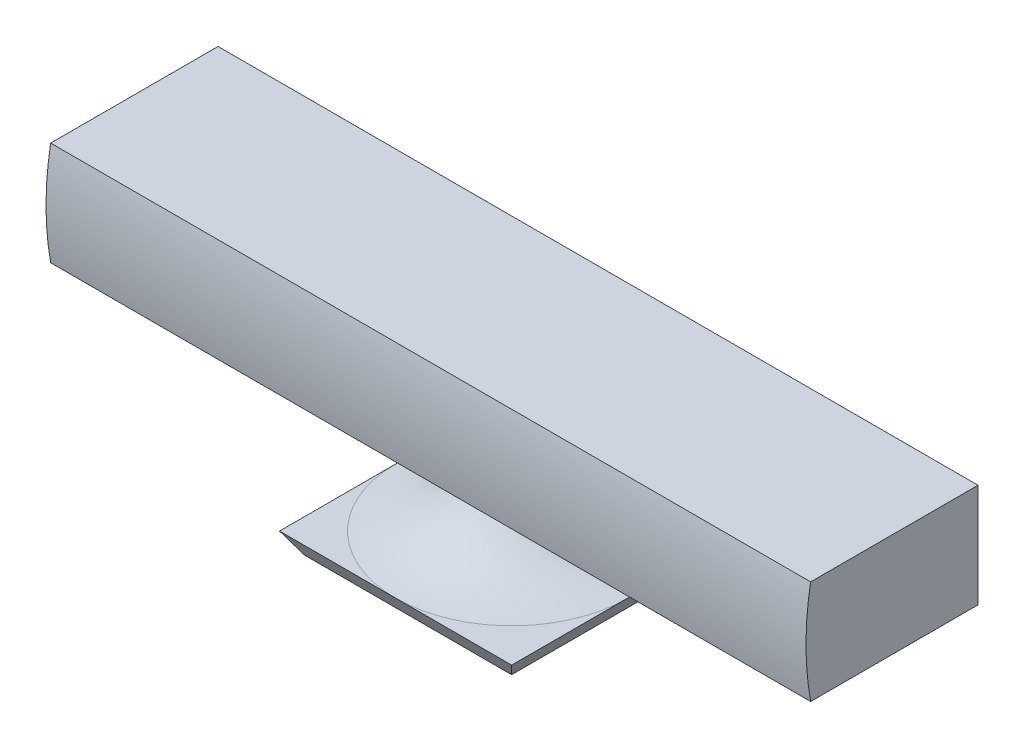
from build123d import *

# Parameters (mm, degrees)
BOSS_EXTRUDE1_DEPTH      = 31.75
BOSS_EXTRUDE1_DEPTH_BACK = 31.75
SKETCH1_W                = 279.4
SKETCH1_H                = 38.1
SKETCH2_W                = 85.344
SKETCH2_H                = 85.344
BOSS_EXTRUDE2_DEPTH      = 38.1
CUT_EXTRUDE3_DEPTH       = 174.39495625
CUT_EXTRUDE4_DEPTH       = 157.853792088
CUT_EXTRUDE4_DEPTH_BACK  = 157.853792088
CUT_EXTRUDE5_DEPTH       = 289.359813588


with BuildPart() as part:
    # Sketch1 → Boss-Extrude1 (new, two sides: drawn at the far end of the back side and taken through both)
    with BuildSketch(Plane.XY.offset(-BOSS_EXTRUDE1_DEPTH_BACK)):
        Rectangle(SKETCH1_W, SKETCH1_H)
    extrude(amount=BOSS_EXTRUDE1_DEPTH + BOSS_EXTRUDE1_DEPTH_BACK)

    # Sketch2 → Boss-Extrude2 (add)
    with BuildSketch(Plane.XZ.offset(19.05)):
        Rectangle(SKETCH2_W, SKETCH2_H)
    extrude(amount=BOSS_EXTRUDE2_DEPTH)

    # Sketch3 → Cut-Revolve8 (revolve, cut)
    with BuildSketch(Plane.XY):
        with BuildLine():
            Line((-42.672, -49.517710244), (-67.10297317, -49.517710244))
            Line((-67.10297317, -49.517710244), (-67.10297317, -19.05))
            Line((-67.10297317, -19.05), (-6.167552681, -19.05))
            add(Edge.make_bspline(
                [(-42.672, -49.517710244), (-14.406584367, -46.12312834), (-6.167552681, -19.05)],
                knots=[0, 0, 0, 1, 1, 1], degree=2))
        make_face()
    revolve(axis=Axis((0, -19.05, 0), (0, -1, 0)), mode=Mode.SUBTRACT)

    # Sketch5 → Cut-Extrude3 (cut, through all)
    with BuildSketch(Plane.XY.offset(42.672)):
        Polygon((-38.1, -57.15), (-42.672, -49.517710244), (-42.672, -57.15), align=None)
        Polygon((38.1, -57.15), (42.672, -49.517710244), (42.672, -57.15), align=None)
    extrude(amount=-CUT_EXTRUDE3_DEPTH, mode=Mode.SUBTRACT)

    # Sketch6 → Cut-Extrude4 (cut, two sides: drawn at the far end of the back side and taken through both)
    with BuildSketch(Plane(origin=(0, 0, 0), x_dir=(0, 0, -1), z_dir=(1, 0, 0)).offset(-CUT_EXTRUDE4_DEPTH_BACK)):
        Polygon((-42.672, -49.517710244), (-42.672, -57.15), (-38.1, -57.15), align=None)
        Polygon((42.672, -49.517710244), (42.672, -57.15), (38.1, -57.15), align=None)
    extrude(amount=CUT_EXTRUDE4_DEPTH + CUT_EXTRUDE4_DEPTH_BACK, mode=Mode.SUBTRACT)

    # Sketch7 → Cut-Extrude5 (cut, through all)
    with BuildSketch(Plane(origin=(139.7, 0, 0), x_dir=(0, 0, -1), z_dir=(1, 0, 0))):
        with BuildLine():
            Line((-29.778395533, 19.05), (-31.75, 19.05))
            Line((-31.75, 19.05), (-31.75, -19.05))
            Line((-31.75, -19.05), (-29.778395533, -19.05))
            add(Edge.make_bspline(
                [(-29.778395533, 19.05), (-33.222300303, -0.003701855), (-29.778395533, -19.05)],
                knots=[0, 0, 0, 1, 1, 1], degree=2))
        make_face()
    extrude(amount=-CUT_EXTRUDE5_DEPTH, mode=Mode.SUBTRACT)


solid = part.part
